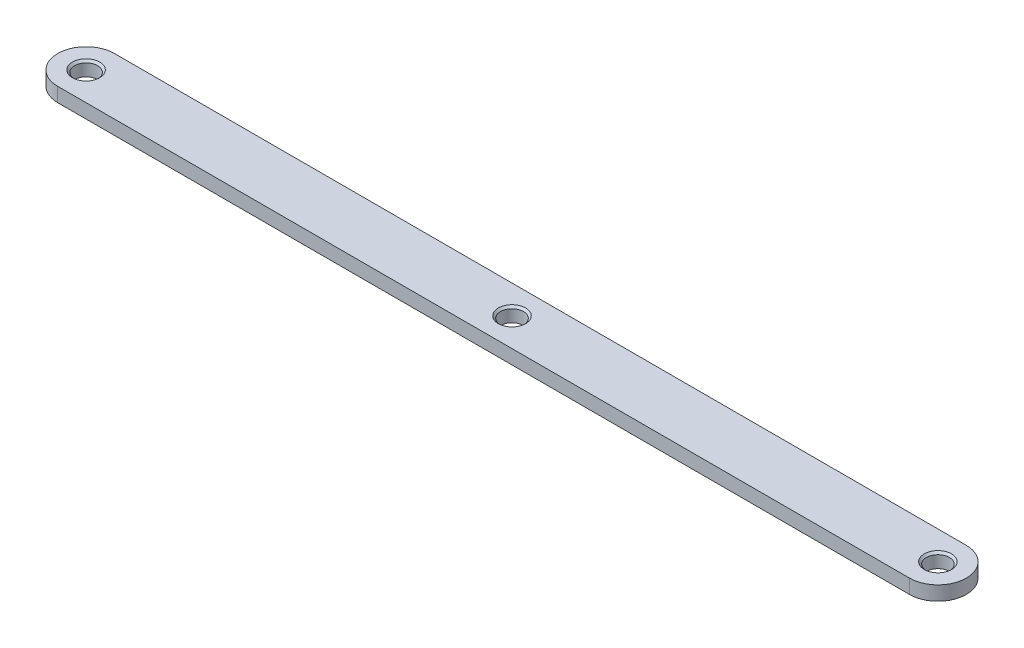
from build123d import *

# Parameters (mm, degrees)
SKETCH1_R                        = 2.5796875
BOSS_EXTRUDE1_DEPTH              = 3.175
F_10_32_TAPPED_HOLE1_D           = 4.0386
F_10_32_TAPPED_HOLE1_CSINK_D     = 6.096
F_10_32_TAPPED_HOLE1_CSINK_ANGLE = 90


with BuildPart() as part:
    # Sketch1 → Boss-Extrude1 (new body)
    with BuildSketch(Plane(origin=(0, 0, 0), x_dir=(1, 0, 0), z_dir=(0, 1, 0))):
        with BuildLine():
            Line((-95.25, 6.35), (95.25, 6.35))
            ThreePointArc((95.25, 6.35), (101.6, 0), (95.25, -6.35))
            Line((95.25, -6.35), (-95.25, -6.35))
            ThreePointArc((-95.25, -6.35), (-101.6, 0), (-95.25, 6.35))
        make_face()
        with Locations((95.25, 0)):
            Circle(SKETCH1_R, mode=Mode.SUBTRACT)
        with Locations((-95.25, 0)):
            Circle(SKETCH1_R, mode=Mode.SUBTRACT)
        Circle(SKETCH1_R, mode=Mode.SUBTRACT)
    extrude(amount=BOSS_EXTRUDE1_DEPTH)

    # #10-32 Tapped Hole1 (through all)
    with Locations(Plane(origin=(0, 3.175, 0), x_dir=(1, 0, 0), z_dir=(0, 1, 0))):
        with Locations((-95.25, 0), (0, 0), (95.25, 0)):
            CounterSinkHole(F_10_32_TAPPED_HOLE1_D / 2, F_10_32_TAPPED_HOLE1_CSINK_D / 2, counter_sink_angle=F_10_32_TAPPED_HOLE1_CSINK_ANGLE)


solid = part.part
